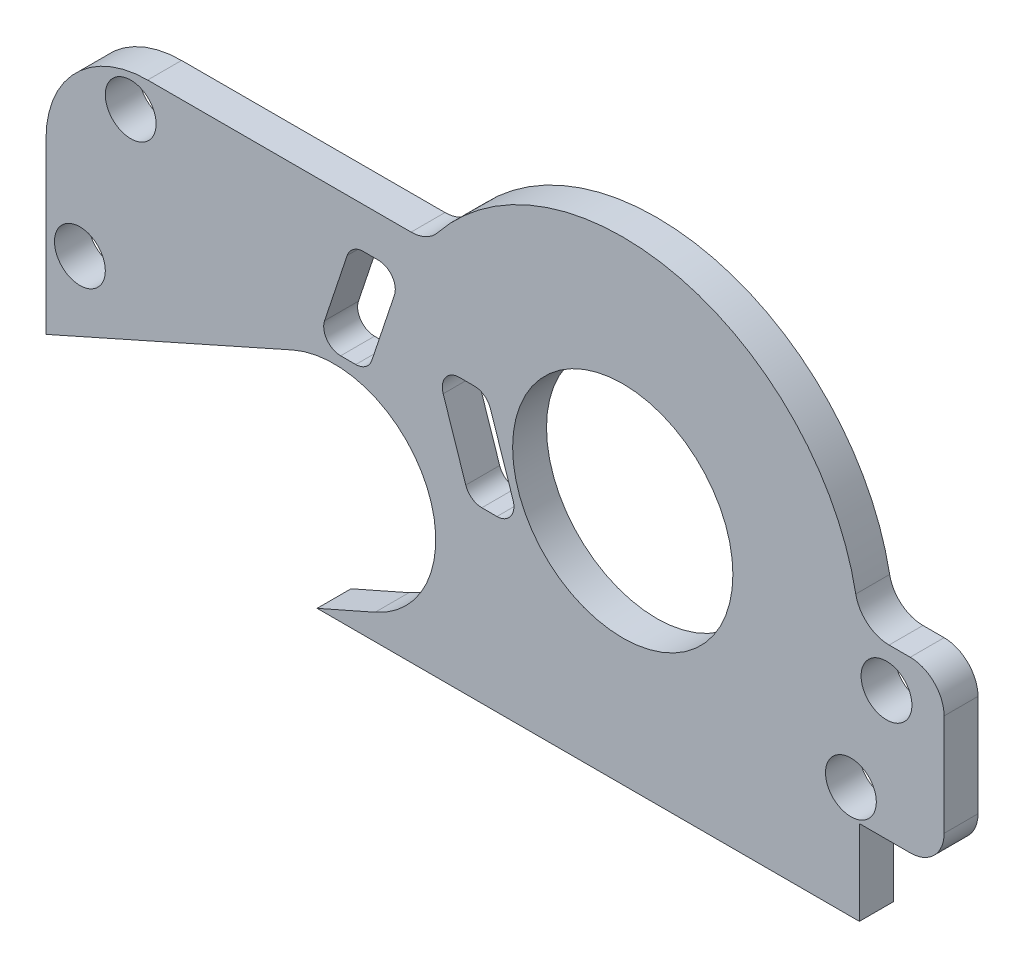
from build123d import *

# Parameters (mm, degrees)
BOSS_EXTRUDE1_DEPTH = 1
SKETCH3_R           = 3.25
CUT_EXTRUDE2_DEPTH  = 10
SKETCH4_R           = 0.75
CUT_EXTRUDE3_DEPTH  = 10


with BuildPart() as part:
    # Sketch1 → Boss-Extrude1 (new body)
    with BuildSketch(Plane.XY):
        with BuildLine():
            Line((-17.017879978, -7), (6.982120022, -7))
            Line((6.982120022, -7), (6.982120022, -5.5))
            Line((6.982120022, -5.5), (6.982120022, -4.5))
            Line((6.982120022, -4.5), (7.982120022, -4.5))
            Line((7.982120022, -4.5), (8.482120022, -4.5))
            ThreePointArc((8.482120022, -4.5), (9.189226803, -4.207106781), (9.482120022, -3.5))
            Line((9.482120022, -3.5), (9.482120022, -0.5))
            ThreePointArc((9.482120022, -0.5), (9.189226803, 0.207106781), (8.482120022, 0.5))
            Line((8.482120022, 0.5), (7.858116823, 0.5))
            ThreePointArc((7.858116823, 0.5), (7.220739384, 0.72944825), (6.87585222, 1.3125))
            ThreePointArc((6.87585222, 1.3125), (1.68605895, 6.793909421), (-5.464373249, 4.375))
            ThreePointArc((-5.464373249, 4.375), (-5.811985297, 4.098612181), (-6.244997998, 4))
            Line((-6.244997998, 4), (-14.017879978, 4))
            ThreePointArc((-14.017879978, 4), (-16.139200322, 3.121320344), (-17.017879978, 1))
            Line((-17.017879978, 1), (-17.017879978, -7))
        make_face()
    extrude(amount=BOSS_EXTRUDE1_DEPTH)

    # Sketch3 → Cut-Extrude2 (cut)
    with BuildSketch(Plane.XY.offset(1)):
        with BuildLine():
            Line((-9.737921814, -0.759288793), (-17.017879978, -4))
            Line((-17.017879978, -4), (-17.017879978, -7))
            Line((-17.017879978, -7), (-9.017879978, -7))
            Line((-9.017879978, -7), (-7.306383876, -6.244499443))
            ThreePointArc((-7.306383876, -6.244499443), (-5.775271325, -2.284229555), (-9.737921814, -0.759288793))
        make_face()
        with BuildLine():
            ThreePointArc((-8.131842017, 2.458113883), (-7.94985551, 2.705621093), (-7.657500368, 2.8))
            Line((-7.657500368, 2.8), (-7.211592921, 2.8))
            ThreePointArc((-7.211592921, 2.8), (-6.805971829, 2.592355142), (-6.737251272, 2.141886117))
            Line((-6.737251272, 2.141886117), (-7.403917939, 0.141886117))
            ThreePointArc((-7.403917939, 0.141886117), (-7.585904446, -0.105621093), (-7.878259588, -0.2))
            Line((-7.878259588, -0.2), (-8.324167035, -0.2))
            ThreePointArc((-8.324167035, -0.2), (-8.729788127, 0.007644858), (-8.798508684, 0.458113883))
            Line((-8.798508684, 0.458113883), (-8.131842017, 2.458113883))
        make_face()
        with BuildLine():
            ThreePointArc((-5.298508684, 0.341886117), (-5.229788127, 0.792355142), (-4.824167035, 1))
            Line((-4.824167035, 1), (-4.378259588, 1))
            ThreePointArc((-4.378259588, 1), (-4.085904446, 0.905621093), (-3.903917939, 0.658113883))
            Line((-3.903917939, 0.658113883), (-3.237251272, -1.341886117))
            ThreePointArc((-3.237251272, -1.341886117), (-3.305971829, -1.792355142), (-3.711592921, -2))
            Line((-3.711592921, -2), (-4.157500368, -2))
            ThreePointArc((-4.157500368, -2), (-4.44985551, -1.905621093), (-4.631842017, -1.658113883))
            Line((-4.631842017, -1.658113883), (-5.298508684, 0.341886117))
        make_face()
        Circle(SKETCH3_R)
    extrude(amount=-CUT_EXTRUDE2_DEPTH, mode=Mode.SUBTRACT)

    # Sketch4 → Cut-Extrude3 (cut)
    with BuildSketch(Plane.XY.offset(1)):
        with Locations((-14.517879978, 3)):
            Circle(SKETCH4_R)
        with Locations((-16.017879978, -1.5)):
            Circle(SKETCH4_R)
        with Locations((7.782120022, -0.7)):
            Circle(SKETCH4_R)
        with Locations((6.732120022, -3.7)):
            Circle(SKETCH4_R)
    extrude(amount=-CUT_EXTRUDE3_DEPTH, mode=Mode.SUBTRACT)


solid = part.part
